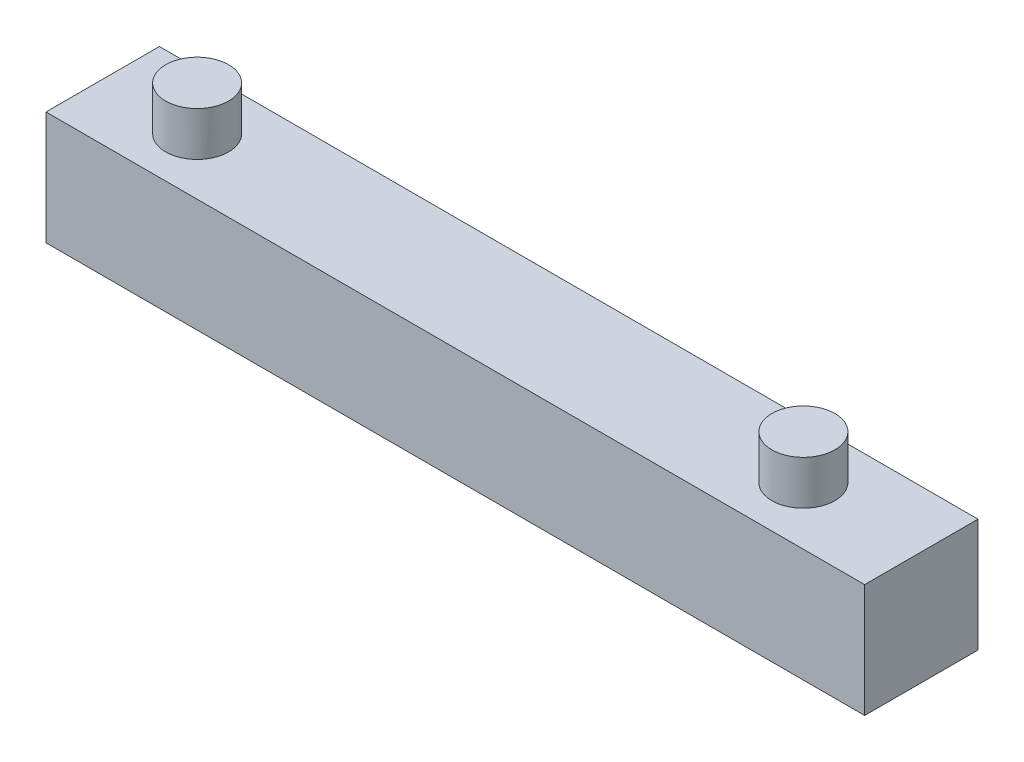
from build123d import *

# Parameters (mm, degrees)
SKETCH1_W           = 65
SKETCH1_H           = 9
BOSS_EXTRUDE1_DEPTH = 9
SKETCH2_R           = 2.5
BOSS_EXTRUDE2_DEPTH = 3.5
SKETCH3_R           = 2.5
BOSS_EXTRUDE3_DEPTH = 3.5


with BuildPart() as part:
    # Sketch1 → Boss-Extrude1 (new body)
    with BuildSketch(Plane.XY):
        with Locations((32.5, 4.5)):
            Rectangle(SKETCH1_W, SKETCH1_H)
    extrude(amount=BOSS_EXTRUDE1_DEPTH)

    # Sketch2 → Boss-Extrude2 (add)
    with BuildSketch(Plane(origin=(0, 0, 0), x_dir=(1, 0, 0), z_dir=(0, 1, 0))):
        with Locations((7.5, -4.5)):
            Circle(SKETCH2_R)
        with Locations((57.5, -4.5)):
            Circle(SKETCH2_R)
    extrude(amount=BOSS_EXTRUDE2_DEPTH)

    # Sketch3 → Boss-Extrude3 (add)
    with BuildSketch(Plane(origin=(0, 9, 0), x_dir=(1, 0, 0), z_dir=(0, 1, 0))):
        with Locations(Location((7.5, -4.5, 0), (0, 0, 90))):  # turned: the seam where the file's is
            Circle(SKETCH3_R)
        with Locations(Location((55.54922584, -4.413995426, 0), (0, 0, 90))):  # turned: the seam where the file's is
            Circle(SKETCH3_R)
    extrude(amount=BOSS_EXTRUDE3_DEPTH)


solid = part.part
